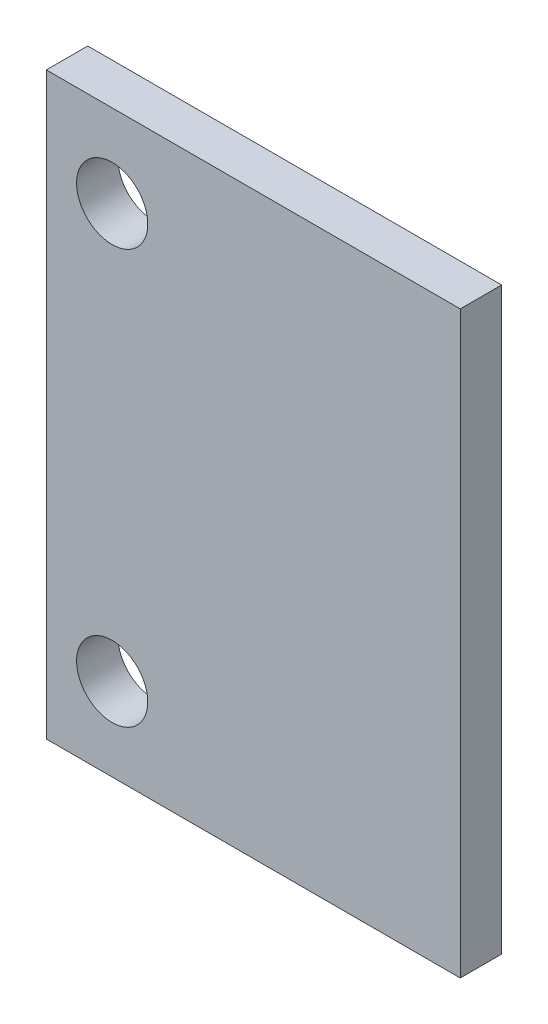
from build123d import *

# Parameters (mm, degrees)
SKETCH1_W           = 12.7
SKETCH1_H           = 17.78
SKETCH1_R           = 1.0922
BOSS_EXTRUDE1_DEPTH = 0.635


with BuildPart() as part:
    # Sketch1 → Boss-Extrude1 (new body, symmetric)
    with BuildSketch(Plane.XY):
        Rectangle(SKETCH1_W, SKETCH1_H)
        with Locations((-4.330703088, 6.35)):
            Circle(SKETCH1_R, mode=Mode.SUBTRACT)
        with Locations((-4.330703088, -6.35)):
            Circle(SKETCH1_R, mode=Mode.SUBTRACT)
    extrude(amount=BOSS_EXTRUDE1_DEPTH, both=True)


solid = part.part
